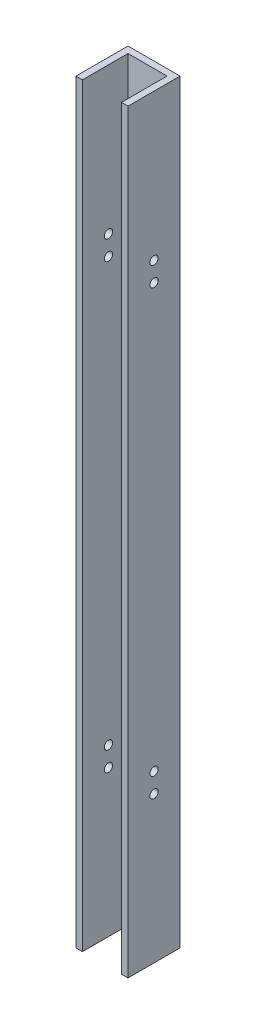
from build123d import *

# Parameters (mm, degrees)
BOSS_EXTRUDE1_DEPTH = 368.3
SKETCH2_R           = 2.032
CUT_EXTRUDE1_DEPTH  = 25.4


with BuildPart() as part:
    # Sketch1 → Boss-Extrude1 (new body)
    with BuildSketch(Plane(origin=(0, 0, 0), x_dir=(1, 0, 0), z_dir=(0, 1, 0))):
        Polygon((0, 0), (3.175, 0), (3.175, 22.225), (22.225, 22.225), (22.225, 0), (25.4, 0), (25.4, 25.4), (0, 25.4), align=None)
    extrude(amount=BOSS_EXTRUDE1_DEPTH)

    # Sketch2 → Cut-Extrude1 (cut)
    with BuildSketch(Plane.ZY):
        with Locations((-12.7, 71.4375)):
            Circle(SKETCH2_R)
        with Locations((-12.7, 296.8625)):
            Circle(SKETCH2_R)
        with Locations((-12.7, 287.3375)):
            Circle(SKETCH2_R)
        with Locations((-12.7, 80.9625)):
            Circle(SKETCH2_R)
    extrude(amount=-CUT_EXTRUDE1_DEPTH, mode=Mode.SUBTRACT)


solid = part.part
